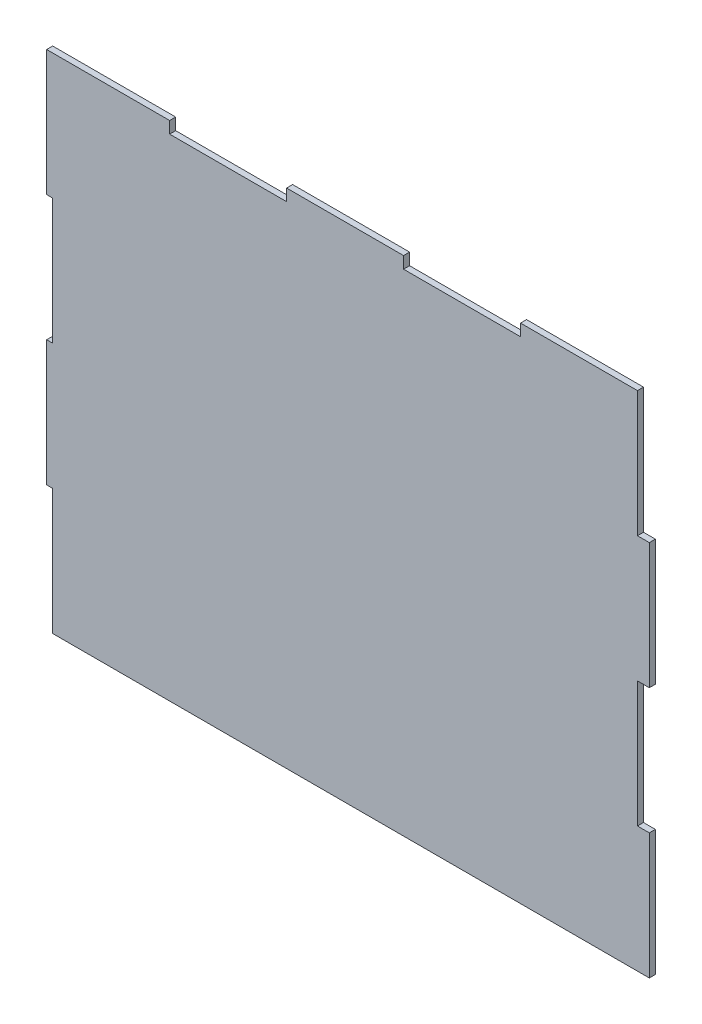
from build123d import *

# Parameters (mm, degrees)
BOSS_EXTRUDE1_DEPTH = 3.048


with BuildPart() as part:
    # Sketch1 → Boss-Extrude1 (new body)
    with BuildSketch(Plane.XY):
        Polygon((-3.048, 63.5), (-3.048, 127), (0, 127), (0, 190.5), (-3.048, 190.5), (-3.048, 253.981711342), (59.0804, 253.981711342), (59.0804, 248.012711342), (118.1608, 248.012711342), (118.1608, 253.981711342), (177.2412, 253.981711342), (177.2412, 248.012711342), (236.3216, 248.012711342), (236.3216, 253.981711342), (295.402, 253.981711342), (295.402, 190.481711342), (301.3964, 190.481711342), (301.3964, 126.981711342), (295.402, 126.981711342), (295.402, 63.5), (301.3964, 63.5), (301.3964, 0), (0, 0), (0, 63.5), align=None)
    extrude(amount=BOSS_EXTRUDE1_DEPTH)


solid = part.part
